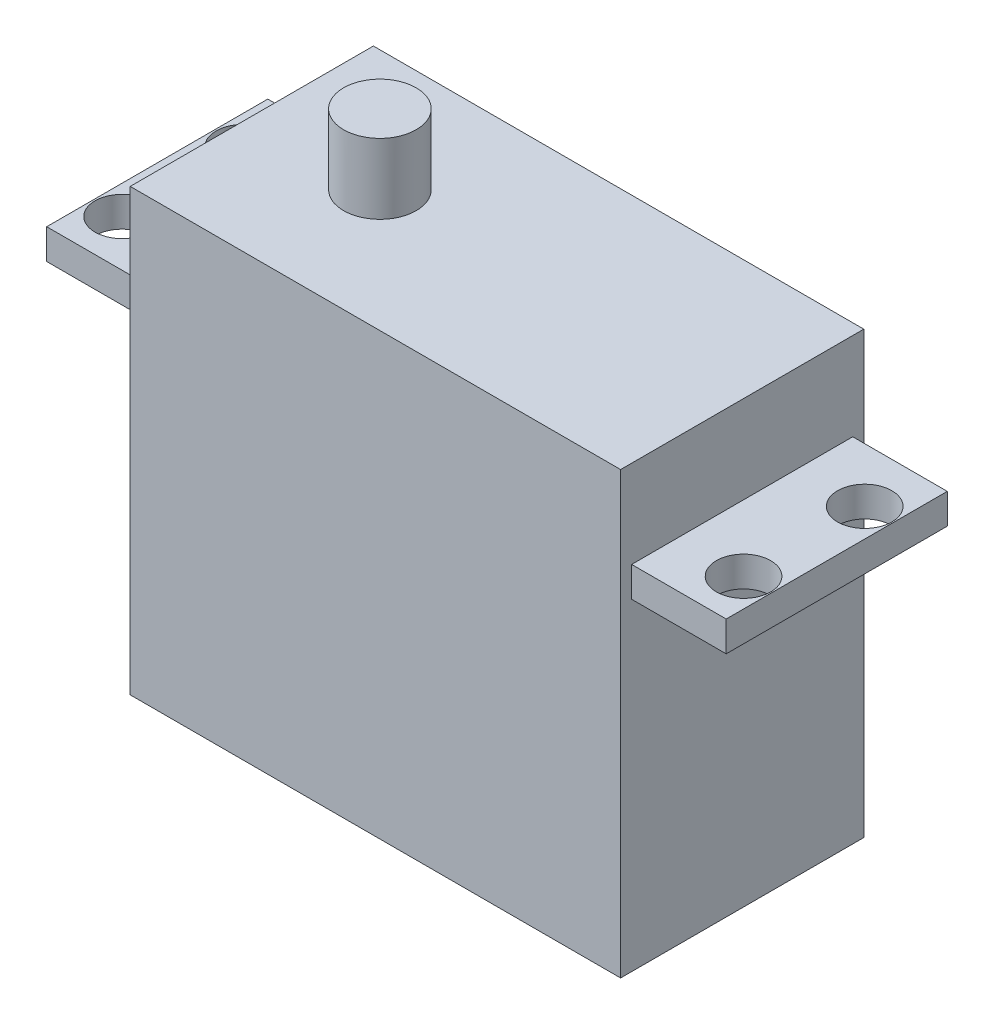
from build123d import *

# Parameters (mm, degrees)
SKETCH1_W           = 55.499
SKETCH1_H           = 35.9664
BOSS_EXTRUDE1_DEPTH = 19.8628
SKETCH2_W           = 7.7216
SKETCH2_H           = 7.1628
SKETCH2_H_2         = 26.3398
CUT_EXTRUDE1_DEPTH  = 19.8628
SKETCH3_W           = 7.7216
SKETCH3_H           = 7.1628
SKETCH3_H_2         = 26.3398
CUT_EXTRUDE2_DEPTH  = 19.8628
SKETCH4_R           = 2.21615
CUT_EXTRUDE3_DEPTH  = 2.4638
SKETCH5_W           = 7.7216
SKETCH5_H           = 2.4638
CUT_EXTRUDE4_DEPTH  = 0.9017
SKETCH6_W           = 7.7216
SKETCH6_H           = 2.4638
CUT_EXTRUDE5_DEPTH  = 0.9017
SKETCH7_W           = 7.7216
SKETCH7_H           = 2.4638
CUT_EXTRUDE6_DEPTH  = 0.9017
SKETCH8_W           = 7.7216
SKETCH8_H           = 2.4638
CUT_EXTRUDE7_DEPTH  = 0.9017
SKETCH9_R           = 2.96545
BOSS_EXTRUDE2_DEPTH = 5.7277


with BuildPart() as part:
    # Sketch1 → Boss-Extrude1 (new body)
    with BuildSketch(Plane.XY):
        with Locations((-27.7495, -17.9832)):
            Rectangle(SKETCH1_W, SKETCH1_H)
    extrude(amount=BOSS_EXTRUDE1_DEPTH)

    # Sketch2 → Cut-Extrude1 (cut)
    with BuildSketch(Plane.XY.offset(19.8628)):
        with Locations((-51.6382, -3.5814)):
            Rectangle(SKETCH2_W, SKETCH2_H)
        with Locations((-51.6382, -22.7965)):
            Rectangle(SKETCH2_W, SKETCH2_H_2)
    extrude(amount=-CUT_EXTRUDE1_DEPTH, mode=Mode.SUBTRACT)

    # Sketch3 → Cut-Extrude2 (cut)
    with BuildSketch(Plane.XY.offset(19.8628)):
        with Locations((-3.8608, -3.5814)):
            Rectangle(SKETCH3_W, SKETCH3_H)
        with Locations((-3.8608, -22.7965)):
            Rectangle(SKETCH3_W, SKETCH3_H_2)
    extrude(amount=-CUT_EXTRUDE2_DEPTH, mode=Mode.SUBTRACT)

    # Sketch4 → Cut-Extrude3 (cut)
    with BuildSketch(Plane(origin=(0, -7.1628, 0), x_dir=(1, 0, 0), z_dir=(0, 1, 0))):
        with Locations((-53.14315, -5.26415)):
            Circle(SKETCH4_R)
        with Locations((-53.14315, -15.15745)):
            Circle(SKETCH4_R)
        with Locations((-2.314703143, -5.334451514)):
            Circle(SKETCH4_R)
        with Locations((-2.314703143, -15.227751514)):
            Circle(SKETCH4_R)
    extrude(amount=-CUT_EXTRUDE3_DEPTH, mode=Mode.SUBTRACT)

    # Sketch5 → Cut-Extrude4 (cut)
    with BuildSketch(Plane.XY.offset(19.8628)):
        with Locations((-51.6382, -8.3947)):
            Rectangle(SKETCH5_W, SKETCH5_H)
    extrude(amount=-CUT_EXTRUDE4_DEPTH, mode=Mode.SUBTRACT)

    # Sketch6 → Cut-Extrude5 (cut)
    with BuildSketch(Plane(origin=(0, 0, 0), x_dir=(-1, 0, 0), z_dir=(0, 0, -1))):
        with Locations((51.6382, -8.3947)):
            Rectangle(SKETCH6_W, SKETCH6_H)
    extrude(amount=-CUT_EXTRUDE5_DEPTH, mode=Mode.SUBTRACT)

    # Sketch7 → Cut-Extrude6 (cut)
    with BuildSketch(Plane(origin=(0, 0, 0), x_dir=(-1, 0, 0), z_dir=(0, 0, -1))):
        with Locations((3.8608, -8.3947)):
            Rectangle(SKETCH7_W, SKETCH7_H)
    extrude(amount=-CUT_EXTRUDE6_DEPTH, mode=Mode.SUBTRACT)

    # Sketch8 → Cut-Extrude7 (cut)
    with BuildSketch(Plane.XY.offset(19.8628)):
        with Locations((-3.8608, -8.3947)):
            Rectangle(SKETCH8_W, SKETCH8_H)
    extrude(amount=-CUT_EXTRUDE7_DEPTH, mode=Mode.SUBTRACT)

    # Sketch9 → Boss-Extrude2 (add)
    with BuildSketch(Plane(origin=(0, 0, 0), x_dir=(1, 0, 0), z_dir=(0, 1, 0))):
        with Locations((-37.34435, -9.89965)):
            Circle(SKETCH9_R)
    extrude(amount=BOSS_EXTRUDE2_DEPTH)


solid = part.part
